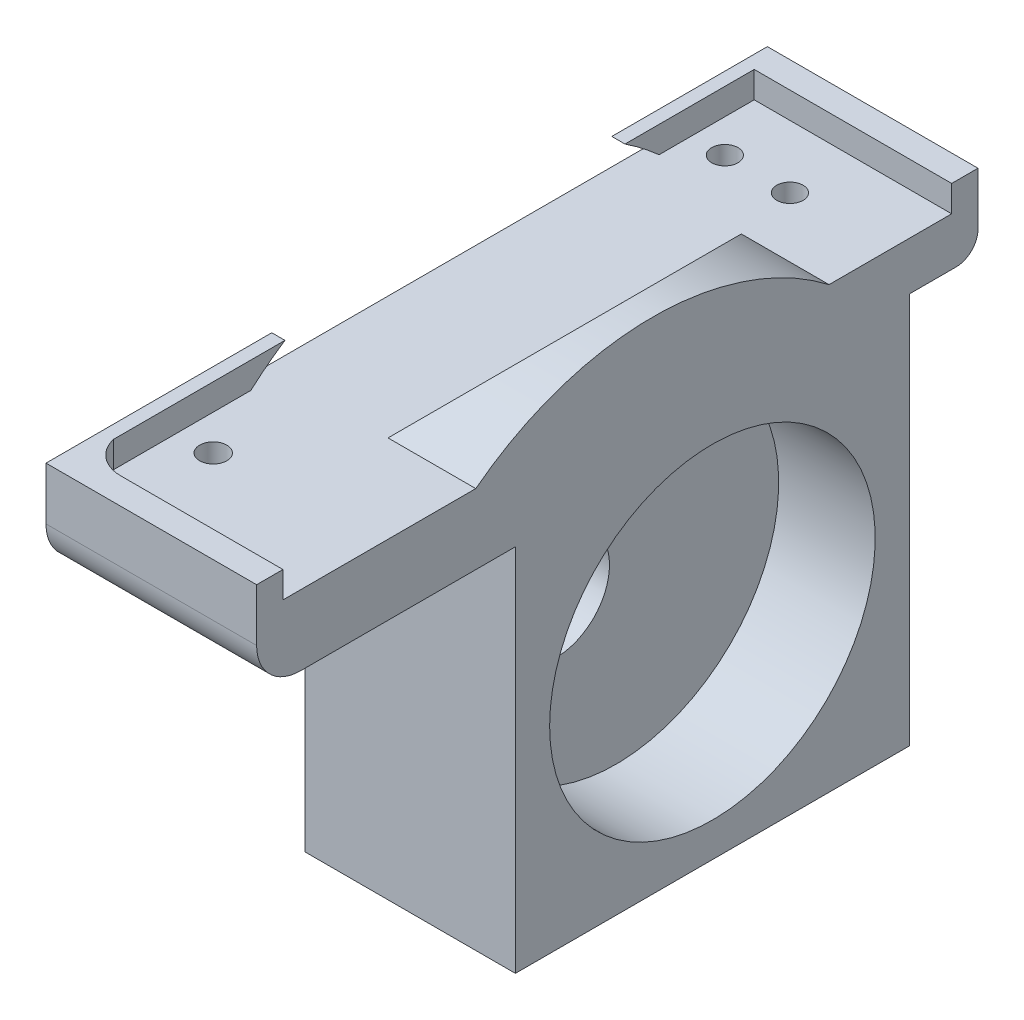
from build123d import *

# Parameters (mm, degrees)
SKETCH1_R           = 22.45
SKETCH1_R_2         = 18.55
SKETCH1_R_3         = 6.11
SKETCH1_R_4         = 5.25
SKETCH1_R_5         = 3.075
BOSS_EXTRUDE1_DEPTH = 5.5
SKETCH1_3_R         = 22.45
SKETCH1_3_R_2       = 18.55
SKETCH1_3_R_3       = 6.11
BOSS_EXTRUDE2_DEPTH = 6
SKETCH1_4_R         = 22.45
SKETCH1_4_R_2       = 18.55
BOSS_EXTRUDE3_DEPTH = 17
BOSS_EXTRUDE4_DEPTH = 10
DRAFT1_ANGLE        = 45
BOSS_EXTRUDE5_DEPTH = 3
SKETCH4_R           = 3.075
BOSS_EXTRUDE6_DEPTH = 1.5
SKETCH3_R           = 1.5
SKETCH3_R_2         = 1.55
CUT_EXTRUDE1_DEPTH  = 11
CUT_EXTRUDE2_START  = -9.6
SKETCH3_4_R         = 1.5
CUT_EXTRUDE2_DEPTH  = 2.6
CUT_EXTRUDE3_START  = -8
SKETCH3_5_R         = 1.55
CUT_EXTRUDE3_DEPTH  = 2.5


with BuildPart() as part:
    # Sketch1 → Boss-Extrude1 (new body)
    with BuildSketch(Plane.ZY.offset(-4.58817912)):
        with BuildLine():
            Line((173.913255387, 21.29653024), (97.713255387, 21.29653024))
            Line((97.713255387, 21.29653024), (97.713255387, 24.29653024))
            Line((97.713255387, 24.29653024), (94.713255387, 24.29653024))
            Line((94.713255387, 24.29653024), (94.713255387, 18.29653024))
            ThreePointArc((94.713255387, 18.29653024), (95.445488434, 16.528763287), (97.213255387, 15.79653024))
            Line((97.213255387, 15.79653024), (102.52576333, 15.79653024))
            Line((102.52576333, 15.79653024), (102.52576333, -6.35346976))
            ThreePointArc((102.52576333, -6.35346976), (124.97576333, 16.09653024), (147.42576333, -6.35346976))
            Line((147.42576333, -6.35346976), (147.42576333, 13.29653024))
            Line((147.42576333, 13.29653024), (171.913255387, 13.29653024))
            ThreePointArc((171.913255387, 13.29653024), (175.448789293, 14.760996334), (176.913255387, 18.29653024))
            Line((176.913255387, 18.29653024), (176.913255387, 24.29653024))
            Line((176.913255387, 24.29653024), (173.913255387, 24.29653024))
            Line((173.913255387, 24.29653024), (173.913255387, 21.29653024))
        make_face()
        with BuildLine():
            ThreePointArc((124.97576333, -28.80346976), (109.101216092, -22.228016998), (102.52576333, -6.35346976))
            Line((102.52576333, -6.35346976), (102.52576333, -28.80346976))
            Line((102.52576333, -28.80346976), (124.97576333, -28.80346976))
        make_face()
        with Locations((124.97576333, -6.35346976)):
            Circle(SKETCH1_R)
        with Locations((124.97576333, -6.35346976)):
            Circle(SKETCH1_R_2, mode=Mode.SUBTRACT)
        with Locations((124.97576333, -6.35346976)):
            Circle(SKETCH1_R_2)
        with Locations((131.813255387, -4.853902367)):
            Circle(SKETCH1_R_3, mode=Mode.SUBTRACT)
        with Locations((131.813255387, -4.853902367)):
            Circle(SKETCH1_R_3)
        with Locations((131.813255387, -4.853902367)):
            Circle(SKETCH1_R_4, mode=Mode.SUBTRACT)
        with Locations((131.813255387, -4.853902367)):
            Circle(SKETCH1_R_4)
        with Locations((131.813255387, -4.853902367)):
            Circle(SKETCH1_R_5, mode=Mode.SUBTRACT)
        with BuildLine():
            Line((147.42576333, -28.80346976), (147.42576333, -6.35346976))
            ThreePointArc((147.42576333, -6.35346976), (140.850310568, -22.228016998), (124.97576333, -28.80346976))
            Line((124.97576333, -28.80346976), (147.42576333, -28.80346976))
        make_face()
    extrude(amount=BOSS_EXTRUDE1_DEPTH)

    # Sketch1_3 → Boss-Extrude2 (add)
    with BuildSketch(Plane.ZY.offset(-4.58817912)):
        with BuildLine():
            Line((173.913255387, 21.29653024), (97.713255387, 21.29653024))
            Line((97.713255387, 21.29653024), (97.713255387, 24.29653024))
            Line((97.713255387, 24.29653024), (94.713255387, 24.29653024))
            Line((94.713255387, 24.29653024), (94.713255387, 18.29653024))
            ThreePointArc((94.713255387, 18.29653024), (95.445488434, 16.528763287), (97.213255387, 15.79653024))
            Line((97.213255387, 15.79653024), (102.52576333, 15.79653024))
            Line((102.52576333, 15.79653024), (102.52576333, -6.35346976))
            ThreePointArc((102.52576333, -6.35346976), (124.97576333, 16.09653024), (147.42576333, -6.35346976))
            Line((147.42576333, -6.35346976), (147.42576333, 13.29653024))
            Line((147.42576333, 13.29653024), (171.913255387, 13.29653024))
            ThreePointArc((171.913255387, 13.29653024), (175.448789293, 14.760996334), (176.913255387, 18.29653024))
            Line((176.913255387, 18.29653024), (176.913255387, 24.29653024))
            Line((176.913255387, 24.29653024), (173.913255387, 24.29653024))
            Line((173.913255387, 24.29653024), (173.913255387, 21.29653024))
        make_face()
        with BuildLine():
            Line((147.42576333, -28.80346976), (147.42576333, -6.35346976))
            ThreePointArc((147.42576333, -6.35346976), (140.850310568, -22.228016998), (124.97576333, -28.80346976))
            Line((124.97576333, -28.80346976), (147.42576333, -28.80346976))
        make_face()
        with Locations((124.97576333, -6.35346976)):
            Circle(SKETCH1_3_R)
        with Locations((124.97576333, -6.35346976)):
            Circle(SKETCH1_3_R_2, mode=Mode.SUBTRACT)
        with Locations((124.97576333, -6.35346976)):
            Circle(SKETCH1_3_R_2)
        with Locations((131.813255387, -4.853902367)):
            Circle(SKETCH1_3_R_3, mode=Mode.SUBTRACT)
    extrude(amount=-BOSS_EXTRUDE2_DEPTH)

    # Sketch1_4 → Boss-Extrude3 (add)
    with BuildSketch(Plane.ZY.offset(-4.58817912)):
        with BuildLine():
            Line((173.913255387, 21.29653024), (97.713255387, 21.29653024))
            Line((97.713255387, 21.29653024), (97.713255387, 24.29653024))
            Line((97.713255387, 24.29653024), (94.713255387, 24.29653024))
            Line((94.713255387, 24.29653024), (94.713255387, 18.29653024))
            ThreePointArc((94.713255387, 18.29653024), (95.445488434, 16.528763287), (97.213255387, 15.79653024))
            Line((97.213255387, 15.79653024), (102.52576333, 15.79653024))
            Line((102.52576333, 15.79653024), (102.52576333, -6.35346976))
            ThreePointArc((102.52576333, -6.35346976), (124.97576333, 16.09653024), (147.42576333, -6.35346976))
            Line((147.42576333, -6.35346976), (147.42576333, 13.29653024))
            Line((147.42576333, 13.29653024), (171.913255387, 13.29653024))
            ThreePointArc((171.913255387, 13.29653024), (175.448789293, 14.760996334), (176.913255387, 18.29653024))
            Line((176.913255387, 18.29653024), (176.913255387, 24.29653024))
            Line((176.913255387, 24.29653024), (173.913255387, 24.29653024))
            Line((173.913255387, 24.29653024), (173.913255387, 21.29653024))
        make_face()
        with BuildLine():
            Line((147.42576333, -28.80346976), (147.42576333, -6.35346976))
            ThreePointArc((147.42576333, -6.35346976), (140.850310568, -22.228016998), (124.97576333, -28.80346976))
            Line((124.97576333, -28.80346976), (147.42576333, -28.80346976))
        make_face()
        with BuildLine():
            ThreePointArc((124.97576333, -28.80346976), (109.101216092, -22.228016998), (102.52576333, -6.35346976))
            Line((102.52576333, -6.35346976), (102.52576333, -28.80346976))
            Line((102.52576333, -28.80346976), (124.97576333, -28.80346976))
        make_face()
        with Locations((124.97576333, -6.35346976)):
            Circle(SKETCH1_4_R)
        with Locations((124.97576333, -6.35346976)):
            Circle(SKETCH1_4_R_2, mode=Mode.SUBTRACT)
    extrude(amount=-BOSS_EXTRUDE3_DEPTH)

    # Sketch2 → Boss-Extrude4 (add)
    with BuildSketch(Plane(origin=(21.58817912, 0, 0), x_dir=(0, 0, -1), z_dir=(1, 0, 0))):
        with BuildLine():
            Line((-151.941714705, 21.29653024), (-111.68479607, 21.29653024))
            ThreePointArc((-111.68479607, 21.29653024), (-131.813255387, 28.146097633), (-151.941714705, 21.29653024))
        make_face()
    extrude(amount=-BOSS_EXTRUDE4_DEPTH)

    # Draft1
    draft1_faces = [part.faces().sort_by_distance(p)[0] for p in [
        (11.58817912, 24.062292156, 131.813255387),
    ]]
    draft(draft1_faces, Plane(origin=(-98.771158707, 21.29653024, 0), x_dir=(1, 0, 0), z_dir=(0, 1, 0)), DRAFT1_ANGLE)

    # Sketch3_3 → Boss-Extrude5 (add)
    with BuildSketch(Plane(origin=(0, 21.29653024, 0), x_dir=(1, 0, 0), z_dir=(0, 1, 0))):
        with BuildLine():
            Line((-0.91182088, -173.913255387), (3.08817912, -173.913255387))
            ThreePointArc((3.08817912, -173.913255387), (0.526929425, -173.014817506), (-0.91182088, -170.713255387))
            Line((-0.91182088, -170.713255387), (-0.91182088, -173.913255387))
        make_face()
    extrude(amount=BOSS_EXTRUDE5_DEPTH)

    # Sketch4 → Boss-Extrude6 (add)
    with BuildSketch(Plane.ZY.offset(0.91182088)):
        with BuildLine():
            Line((97.713255387, 21.29653024), (97.713255387, 24.29653024))
            Line((97.713255387, 24.29653024), (94.713255387, 24.29653024))
            Line((94.713255387, 24.29653024), (94.713255387, 18.29653024))
            ThreePointArc((94.713255387, 18.29653024), (95.445488434, 16.528763287), (97.213255387, 15.79653024))
            Line((97.213255387, 15.79653024), (102.52576333, 15.79653024))
            Line((102.52576333, 15.79653024), (102.52576333, -28.80346976))
            Line((102.52576333, -28.80346976), (147.42576333, -28.80346976))
            Line((147.42576333, -28.80346976), (147.42576333, 13.29653024))
            Line((147.42576333, 13.29653024), (171.913255387, 13.29653024))
            ThreePointArc((171.913255387, 13.29653024), (175.448789293, 14.760996334), (176.913255387, 18.29653024))
            Line((176.913255387, 18.29653024), (176.913255387, 24.29653024))
            Line((176.913255387, 24.29653024), (170.713255387, 24.29653024))
            Line((170.713255387, 24.29653024), (170.713255387, 21.29653024))
            Line((170.713255387, 21.29653024), (155.075991135, 21.29653024))
            Line((155.075991135, 21.29653024), (108.550519639, 21.29653024))
            Line((108.550519639, 21.29653024), (97.713255387, 21.29653024))
        make_face()
        with Locations((131.813255387, -4.853902367)):
            Circle(SKETCH4_R, mode=Mode.SUBTRACT)
        with BuildLine():
            Line((112.44182594, 24.29653024), (97.713255387, 24.29653024))
            Line((97.713255387, 24.29653024), (97.713255387, 21.29653024))
            Line((97.713255387, 21.29653024), (108.550519639, 21.29653024))
            ThreePointArc((108.550519639, 21.29653024), (110.443463379, 22.864899727), (112.44182594, 24.29653024))
        make_face()
        with BuildLine():
            ThreePointArc((151.184684835, 24.29653024), (153.183047396, 22.864899727), (155.075991135, 21.29653024))
            Line((155.075991135, 21.29653024), (170.713255387, 21.29653024))
            Line((170.713255387, 21.29653024), (170.713255387, 24.29653024))
            Line((170.713255387, 24.29653024), (151.184684835, 24.29653024))
        make_face()
    extrude(amount=BOSS_EXTRUDE6_DEPTH)

    # Sketch3 → Cut-Extrude1 (cut)
    with BuildSketch(Plane(origin=(0, 21.29653024, 0), x_dir=(1, 0, 0), z_dir=(0, 1, 0))):
        with Locations(Location((2.879075654, -104.850755387, 0), (0, 0, 180))):
            Circle(SKETCH3_R)
        with Locations(Location((10.297282585, -104.850755387, 0), (0, 0, 180))):
            Circle(SKETCH3_R)
        with Locations(Location((3.11317912, -163.38083505, 0), (0, 0, 180))):
            Circle(SKETCH3_R_2)
    extrude(amount=-CUT_EXTRUDE1_DEPTH, mode=Mode.SUBTRACT)

    # Sketch3_4 → Cut-Extrude2 (cut)
    with BuildSketch(Plane(origin=(0, 21.29653024, 0), x_dir=(1, 0, 0), z_dir=(0, 1, 0)).offset(CUT_EXTRUDE2_START)):
        Polygon((7.447282585, -106.496203654), (10.297282585, -108.141651922), (13.147282585, -106.496203654), (13.147282585, -103.20530712), (11.970278215, -102.52576333), (8.624286956, -102.52576333), (7.447282585, -103.20530712), align=None)
        with Locations(Location((10.297282585, -104.850755387, 0), (0, 0, 180))):
            Circle(SKETCH3_4_R, mode=Mode.SUBTRACT)
        Polygon((11.970278215, -102.52576333), (13.147282585, -103.20530712), (13.147282585, -102.52576333), align=None)
        Polygon((7.447282585, -102.52576333), (7.447282585, -103.20530712), (8.624286956, -102.52576333), align=None)
        Polygon((0.029075654, -106.496203654), (2.879075654, -108.141651922), (5.729075654, -106.496203654), (5.729075654, -103.20530712), (4.552071284, -102.52576333), (1.206080025, -102.52576333), (0.029075654, -103.20530712), align=None)
        with Locations(Location((2.879075654, -104.850755387, 0), (0, 0, 180))):
            Circle(SKETCH3_4_R, mode=Mode.SUBTRACT)
        Polygon((4.552071284, -102.52576333), (5.729075654, -103.20530712), (5.729075654, -102.52576333), align=None)
        Polygon((0.029075654, -102.52576333), (0.029075654, -103.20530712), (1.206080025, -102.52576333), align=None)
    extrude(amount=CUT_EXTRUDE2_DEPTH, mode=Mode.SUBTRACT)

    # Sketch3_5 → Cut-Extrude3 (cut)
    with BuildSketch(Plane(origin=(0, 21.29653024, 0), x_dir=(1, 0, 0), z_dir=(0, 1, 0)).offset(CUT_EXTRUDE3_START)):
        Polygon((4.758627387, -160.53083505), (1.467730853, -160.53083505), (-0.177717415, -163.38083505), (1.467730853, -166.23083505), (4.758627387, -166.23083505), (6.404075654, -163.38083505), align=None)
        with Locations(Location((3.11317912, -163.38083505, 0), (0, 0, 180))):
            Circle(SKETCH3_5_R, mode=Mode.SUBTRACT)
    extrude(amount=CUT_EXTRUDE3_DEPTH, mode=Mode.SUBTRACT)


solid = part.part
